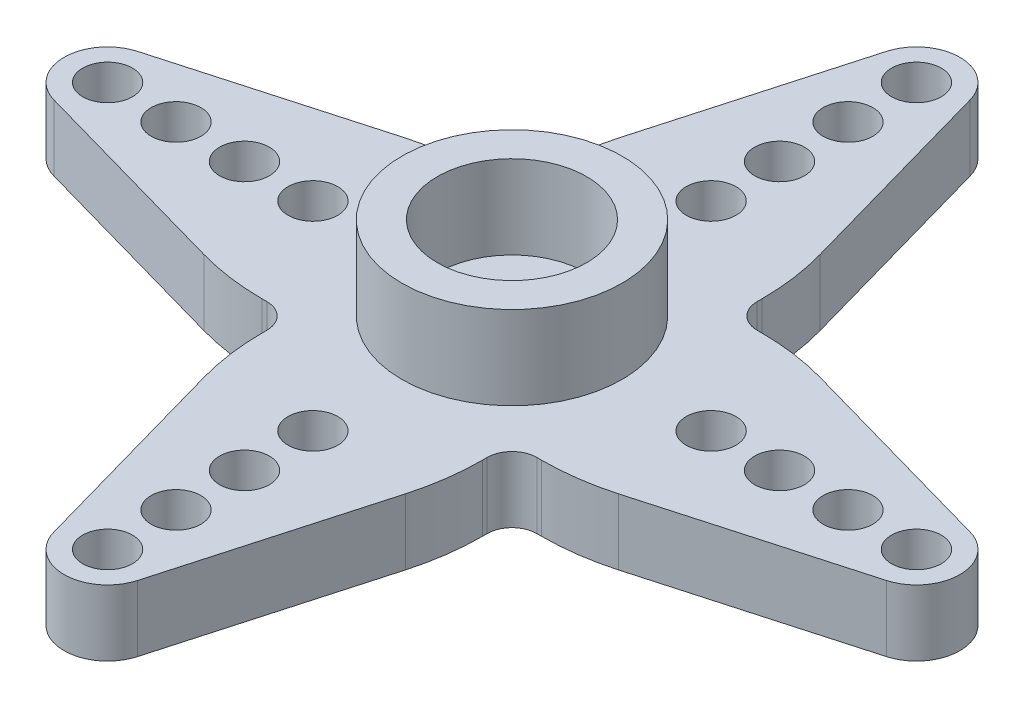
from build123d import *

# Parameters (mm, degrees)
SKETCH1_R             = 1
SKETCH1_R_2           = 4.425
BOSS_EXTRUDE1_DEPTH   = 2.65
SKETCH1_R_3           = 3
BOSS_EXTRUDE1_2_DEPTH = 2.65
SKETCH1_4_R           = 4.425
SKETCH1_4_R_2         = 3
BOSS_EXTRUDE2_DEPTH   = 6
SKETCH2_R             = 4.5
SKETCH2_R_2           = 3.5
SKETCH2_R_3           = 3.25
SKETCH2_R_4           = 1.75
CUT_EXTRUDE1_DEPTH    = 0.2
BOSS_EXTRUDE3_START   = 0.5
SKETCH2_4_R           = 3.5
SKETCH2_4_R_2         = 3.25
BOSS_EXTRUDE3_DEPTH   = 0.5
CUT_EXTRUDE2_REACH    = 79.29
SKETCH2_5_R           = 1.75


with BuildPart() as part:
    # Sketch1 → Boss-Extrude1 (new body)
    with BuildSketch(Plane(origin=(0, 0, 0), x_dir=(1, 0, 0), z_dir=(0, 1, 0))):
        with BuildLine():
            ThreePointArc((-27.745100171, -32.845991913), (-29.088475069, -32.565244357), (-30.457637809, -32.471070591))
            Line((-30.457637809, -32.471070591), (-30.650458566, -32.471070591))
            ThreePointArc((-30.650458566, -32.471070591), (-31.357565348, -32.178177373), (-31.650458566, -31.471070591))
            Line((-31.650458566, -31.471070591), (-31.650458566, -31.278249834))
            ThreePointArc((-31.650458566, -31.278249834), (-31.744632332, -29.909087094), (-32.025379888, -28.565712196))
            Line((-32.025379888, -28.565712196), (-34.391069798, -20.171376505))
            ThreePointArc((-34.391069798, -20.171376505), (-36.075458566, -18.896070591), (-37.759847335, -20.171376505))
            Line((-37.759847335, -20.171376505), (-40.125537245, -28.565712196))
            ThreePointArc((-40.125537245, -28.565712196), (-40.406284801, -29.909087094), (-40.500458566, -31.278249834))
            Line((-40.500458566, -31.278249834), (-40.500458566, -31.471070591))
            ThreePointArc((-40.500458566, -31.471070591), (-40.793351785, -32.178177373), (-41.500458566, -32.471070591))
            Line((-41.500458566, -32.471070591), (-41.693279324, -32.471070591))
            ThreePointArc((-41.693279324, -32.471070591), (-43.062442064, -32.565244357), (-44.405816962, -32.845991913))
            Line((-44.405816962, -32.845991913), (-52.800152653, -35.211681823))
            ThreePointArc((-52.800152653, -35.211681823), (-54.075458566, -36.896070591), (-52.800152653, -38.58045936))
            Line((-52.800152653, -38.58045936), (-44.405816962, -40.94614927))
            ThreePointArc((-44.405816962, -40.94614927), (-43.062442064, -41.226896826), (-41.693279324, -41.321070591))
            Line((-41.693279324, -41.321070591), (-41.500458566, -41.321070591))
            ThreePointArc((-41.500458566, -41.321070591), (-40.793351785, -41.61396381), (-40.500458566, -42.321070591))
            Line((-40.500458566, -42.321070591), (-40.500458566, -42.513891349))
            ThreePointArc((-40.500458566, -42.513891349), (-40.406284801, -43.883054089), (-40.125537245, -45.226428987))
            Line((-40.125537245, -45.226428987), (-37.759847335, -53.620764678))
            ThreePointArc((-37.759847335, -53.620764678), (-36.075458566, -54.896070591), (-34.391069798, -53.620764678))
            Line((-34.391069798, -53.620764678), (-32.025379888, -45.226428987))
            ThreePointArc((-32.025379888, -45.226428987), (-31.744632332, -43.883054089), (-31.650458566, -42.513891349))
            Line((-31.650458566, -42.513891349), (-31.650458566, -42.321070591))
            ThreePointArc((-31.650458566, -42.321070591), (-31.357565348, -41.61396381), (-30.650458566, -41.321070591))
            Line((-30.650458566, -41.321070591), (-30.457637809, -41.321070591))
            ThreePointArc((-30.457637809, -41.321070591), (-29.088475069, -41.226896826), (-27.745100171, -40.94614927))
            Line((-27.745100171, -40.94614927), (-19.35076448, -38.58045936))
            ThreePointArc((-19.35076448, -38.58045936), (-18.075458566, -36.896070591), (-19.35076448, -35.211681823))
            Line((-19.35076448, -35.211681823), (-27.745100171, -32.845991913))
        make_face()
        with Locations((-52.325458566, -36.896070591)):
            Circle(SKETCH1_R, mode=Mode.SUBTRACT)
        with Locations((-49.575458566, -36.896070591)):
            Circle(SKETCH1_R, mode=Mode.SUBTRACT)
        with Locations((-46.825458566, -36.896070591)):
            Circle(SKETCH1_R, mode=Mode.SUBTRACT)
        with Locations((-44.075458566, -36.896070591)):
            Circle(SKETCH1_R, mode=Mode.SUBTRACT)
        with Locations((-36.075458566, -53.146070591)):
            Circle(SKETCH1_R, mode=Mode.SUBTRACT)
        with Locations((-36.075458566, -50.396070591)):
            Circle(SKETCH1_R, mode=Mode.SUBTRACT)
        with Locations((-36.075458566, -47.646070591)):
            Circle(SKETCH1_R, mode=Mode.SUBTRACT)
        with Locations((-36.075458566, -44.896070591)):
            Circle(SKETCH1_R, mode=Mode.SUBTRACT)
        with Locations((-36.075458566, -36.896070591)):
            Circle(SKETCH1_R_2, mode=Mode.SUBTRACT)
        with Locations((-28.075458566, -36.896070591)):
            Circle(SKETCH1_R, mode=Mode.SUBTRACT)
        with Locations((-25.325458566, -36.896070591)):
            Circle(SKETCH1_R, mode=Mode.SUBTRACT)
        with Locations((-22.575458566, -36.896070591)):
            Circle(SKETCH1_R, mode=Mode.SUBTRACT)
        with Locations((-19.825458566, -36.896070591)):
            Circle(SKETCH1_R, mode=Mode.SUBTRACT)
        with Locations((-36.075458566, -28.896070591)):
            Circle(SKETCH1_R, mode=Mode.SUBTRACT)
        with Locations((-36.075458566, -26.146070591)):
            Circle(SKETCH1_R, mode=Mode.SUBTRACT)
        with Locations((-36.075458566, -23.396070591)):
            Circle(SKETCH1_R, mode=Mode.SUBTRACT)
        with Locations((-36.075458566, -20.646070591)):
            Circle(SKETCH1_R, mode=Mode.SUBTRACT)
    extrude(amount=BOSS_EXTRUDE1_DEPTH)

    # Sketch1_4 → Boss-Extrude2 (add)
    with BuildSketch(Plane(origin=(0, 0, 0), x_dir=(1, 0, 0), z_dir=(0, 1, 0))):
        with Locations((-36.075458566, -36.896070591)):
            Circle(SKETCH1_4_R)
        with Locations((-36.075458566, -36.896070591)):
            Circle(SKETCH1_4_R_2, mode=Mode.SUBTRACT)
    extrude(amount=BOSS_EXTRUDE2_DEPTH)


with BuildPart() as body_2:
    # Sketch1 → Boss-Extrude1 2 (new body)
    with BuildSketch(Plane(origin=(0, 0, 0), x_dir=(1, 0, 0), z_dir=(0, 1, 0))):
        with Locations((-36.075458566, -36.896070591)):
            Circle(SKETCH1_R_3)
    extrude(amount=BOSS_EXTRUDE1_2_DEPTH)


with BuildPart() as cut_extrude1_tool:
    # Sketch2 → Cut-Extrude1 (new body)
    # profile 1 of 2: a face of its own
    with BuildSketch(Plane.XZ):
        with Locations((-36.075458566, 36.896070591)):
            Circle(SKETCH2_R)
        with Locations((-36.075458566, 36.896070591)):
            Circle(SKETCH2_R_2, mode=Mode.SUBTRACT)
    # profile 2 of 2: a face of its own
    with BuildSketch(Plane.XZ):
        with Locations((-36.075458566, 36.896070591)):
            Circle(SKETCH2_R_3)
        with Locations((-36.075458566, 36.896070591)):
            Circle(SKETCH2_R_4, mode=Mode.SUBTRACT)
    extrude(amount=-CUT_EXTRUDE1_DEPTH)


with BuildPart() as part_1:
    add(part.part)

    # Cut-Extrude1: cut by cut_extrude1_tool
    add(cut_extrude1_tool.part, mode=Mode.SUBTRACT)



with BuildPart() as body_2_1:
    add(body_2.part)

    # Cut-Extrude1: cut by cut_extrude1_tool
    add(cut_extrude1_tool.part, mode=Mode.SUBTRACT)


with BuildPart() as part_2:
    add(part_1.part)

    add(body_2_1.part)  # Boss-Extrude3 merges body 2
    # Sketch2_4 → Boss-Extrude3 (add)
    with BuildSketch(Plane.XZ.offset(BOSS_EXTRUDE3_START)):
        with Locations((-36.075458566, 36.896070591)):
            Circle(SKETCH2_4_R)
        with Locations((-36.075458566, 36.896070591)):
            Circle(SKETCH2_4_R_2, mode=Mode.SUBTRACT)
    extrude(amount=-BOSS_EXTRUDE3_DEPTH)

    # Sketch2_5 → Cut-Extrude2 (cut, up to next)
    with BuildSketch(Plane.XZ, mode=Mode.PRIVATE) as cut_extrude2_sk1:
        with Locations((-36.075458566, 36.896070591)):
            Circle(SKETCH2_5_R)
    cut_extrude2_tool1 = extrude(cut_extrude2_sk1.sketch, amount=-CUT_EXTRUDE2_REACH, mode=Mode.PRIVATE) & part_2.part
    add(cut_extrude2_tool1.solids().sort_by_distance((-36.075459, 0, 36.896071))[0], mode=Mode.SUBTRACT)


solid = part_2.part
